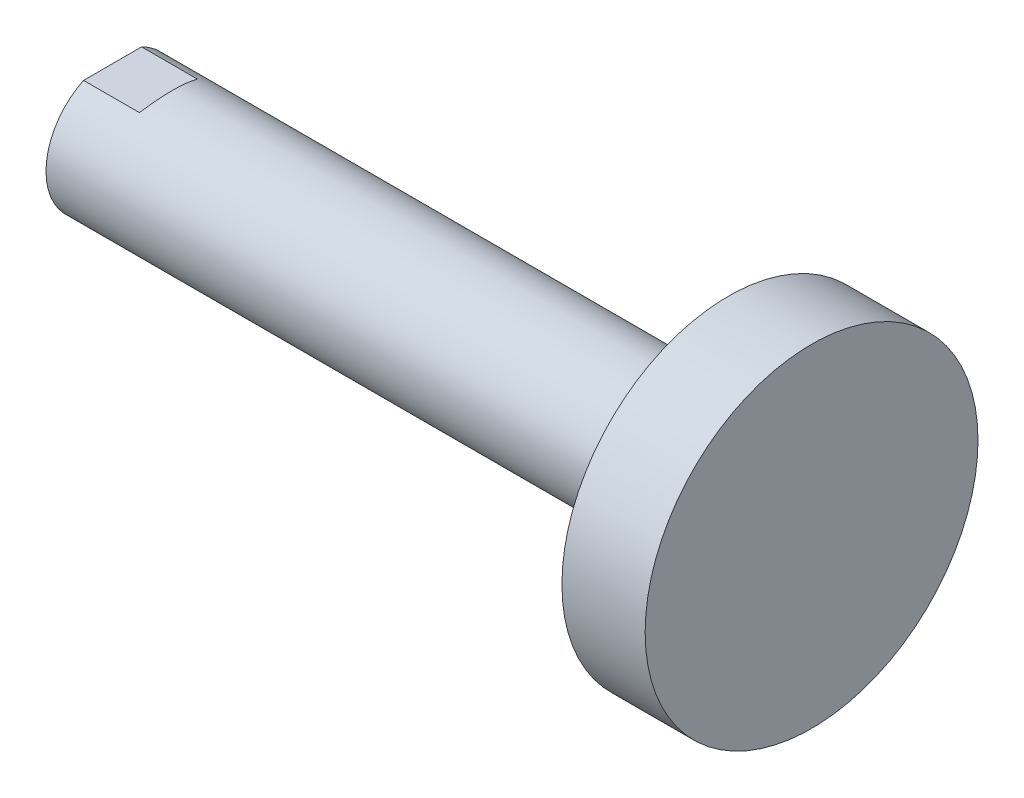
from build123d import *

# Parameters (mm, degrees)
SKIZZE1_W                            = 52.5
SKIZZE1_H                            = 5
SKIZZE2_W                            = 6.25
SKIZZE2_H                            = 12.5
SCHNITT_LINEAR_AUSTRAGEN1_DEPTH      = 10
SCHNITT_LINEAR_AUSTRAGEN1_DEPTH_BACK = 10


with BuildPart() as part:
    # Skizze1 → Rotation1 (revolve)
    with BuildSketch(Plane.XY):
        with Locations((20.75, 2.5)):
            Rectangle(SKIZZE1_W, SKIZZE1_H)
    revolve(axis=Axis((47, 0, 0), (-1, 0, 0)))

    # Skizze2 → Rotation2 (revolve)
    with BuildSketch(Plane.XY):
        with Locations((43.875, 6.25)):
            Rectangle(SKIZZE2_W, SKIZZE2_H)
    revolve(axis=Axis((47, 0, 0), (-1, 0, 0)))

    # Skizze3 → Schnitt-Linear austragen1 (cut, two sides: drawn at the far end of the back side and taken through both)
    with BuildSketch(Plane.XY.offset(-SCHNITT_LINEAR_AUSTRAGEN1_DEPTH_BACK)):
        Polygon((-32, -14.5), (4.473502692, -14.5), (-1.3, -4.5), (-5.5, -4.5), (-5.5, -9.5), (-26.5, -9.5), (-26.5, 9.5), (-5.5, 9.5), (-5.5, 4.5), (-1.3, 4.5), (4.473502692, 14.5), (-32, 14.5), align=None)
    extrude(amount=SCHNITT_LINEAR_AUSTRAGEN1_DEPTH + SCHNITT_LINEAR_AUSTRAGEN1_DEPTH_BACK, mode=Mode.SUBTRACT)

    # Skizze4 → Schnitt-Rotation1 (revolve, cut)
    with BuildSketch(Plane.XY):
        Polygon((-5.5, 0), (-5.5, 3.6), (-5.1, 3.2), (-2.9, 3.2), (-2.9, 3), (-2.3585, 2.4585), (12.5, 2.4585), (13.919415637, 0), align=None)
    revolve(axis=Axis((13.919415637, 0, 0), (-1, 0, 0)), mode=Mode.SUBTRACT)


solid = part.part
